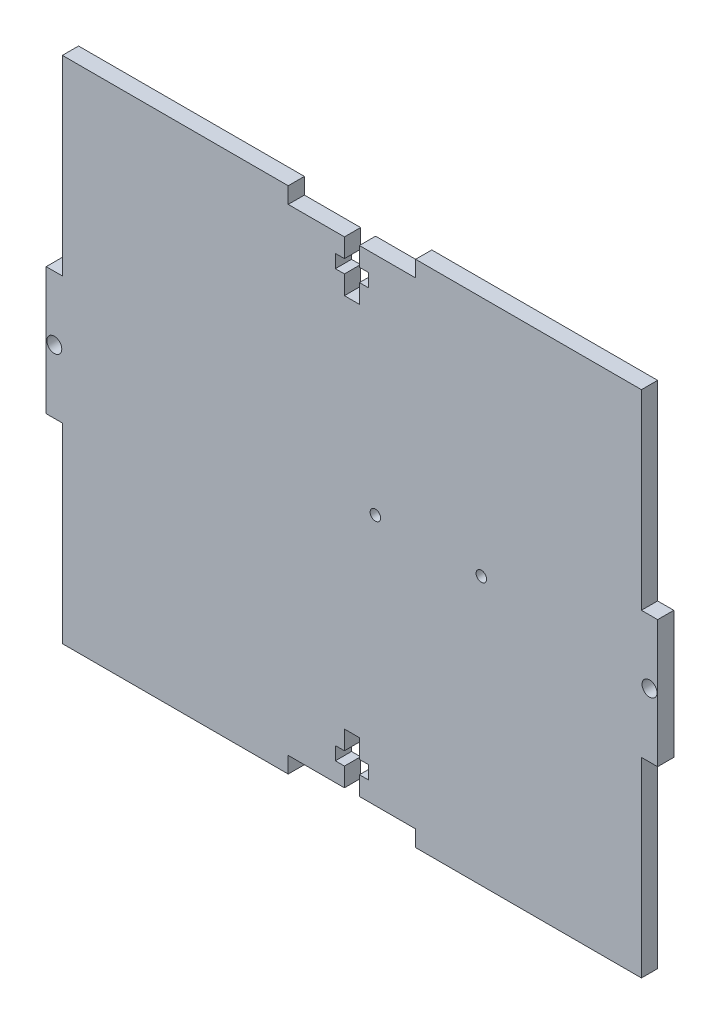
from build123d import *

# Parameters (mm, degrees)
SKETCH1_R           = 1.0287
SKETCH1_R_2         = 1.47
BOSS_EXTRUDE1_DEPTH = 1.5875


with BuildPart() as part:
    # Sketch1 → Boss-Extrude1 (new body, symmetric)
    with BuildSketch(Plane.XY):
        Polygon((-12.5, 50), (-56.825, 50), (-56.825, 12.5), (-60, 12.5), (-60, -12.5), (-56.825, -12.5), (-56.825, -50), (-12.5, -50), (-12.5, -46.825), (-1.47, -46.825), (-1.47, -43.125), (-3.25, -43.125), (-3.25, -40.525), (-1.47, -40.525), (-1.47, -36.825), (1.47, -36.825), (1.47, -40.525), (3.25, -40.525), (3.25, -43.125), (1.47, -43.125), (1.47, -46.825), (12.5, -46.825), (12.5, -50), (56.825, -50), (56.825, -12.5), (60, -12.5), (60, 12.5), (56.825, 12.5), (56.825, 50), (12.5, 50), (12.5, 46.825), (1.47, 46.825), (1.47, 43.125), (3.25, 43.125), (3.25, 40.525), (1.47, 40.525), (1.47, 36.825), (-1.47, 36.825), (-1.47, 40.525), (-3.25, 40.525), (-3.25, 43.125), (-1.47, 43.125), (-1.47, 46.825), (-12.5, 46.825), align=None)
        with Locations((4.6, 2.575)):
            Circle(SKETCH1_R, mode=Mode.SUBTRACT)
        with Locations((25.4, 2.575)):
            Circle(SKETCH1_R, mode=Mode.SUBTRACT)
        with Locations((-58.4125, 0)):
            Circle(SKETCH1_R_2, mode=Mode.SUBTRACT)
        with Locations((58.4125, 0)):
            Circle(SKETCH1_R_2, mode=Mode.SUBTRACT)
    extrude(amount=BOSS_EXTRUDE1_DEPTH, both=True)


solid = part.part
